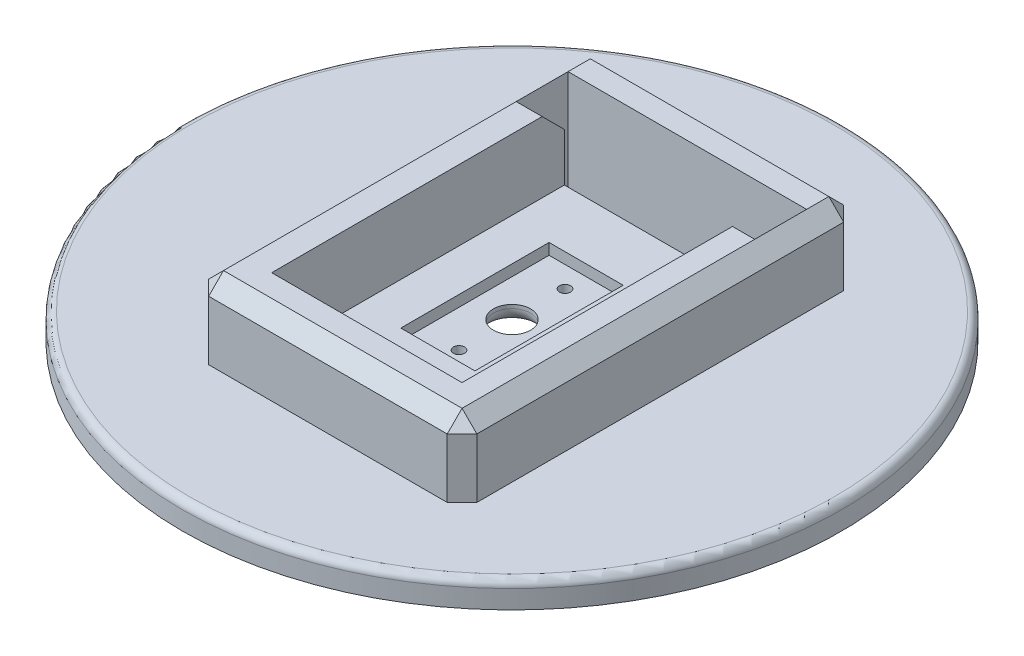
from build123d import *

# Parameters (mm, degrees)
SKETCH1_R           = 44.45
BOSS_EXTRUDE1_DEPTH = 3.5
CUT_EXTRUDE1_DEPTH  = 1
SKETCH3_W           = 25.675
SKETCH3_H           = 43.475
BOSS_EXTRUDE2_DEPTH = 10
SKETCH4_W           = 25.675
SKETCH4_H           = 4
CUT_EXTRUDE2_DEPTH  = 13
SKETCH5_R           = 0.75
CUT_EXTRUDE3_DEPTH  = 13
SKETCH6_R           = 2.5
CUT_EXTRUDE4_DEPTH  = 13
FILLET1_R           = 1
CHAMFER1_SIZE       = 2
FILLET2_R           = 2
SKETCH8_W           = 3.5
SKETCH8_H           = 4
CUT_EXTRUDE6_DEPTH  = 14.5000001
SKETCH10_W          = 3
SKETCH10_H          = 4
CUT_EXTRUDE7_DEPTH  = 14.5000001
CHAMFER2_SIZE       = 3
SKETCH11_W          = 25.675
SKETCH11_H          = 39.475
BOSS_EXTRUDE3_DEPTH = 1.5


with BuildPart() as part:
    # Sketch1 → Boss-Extrude1 (new body)
    with BuildSketch(Plane(origin=(0, 0, 0), x_dir=(1, 0, 0), z_dir=(0, 1, 0))):
        Circle(SKETCH1_R)
    extrude(amount=BOSS_EXTRUDE1_DEPTH)

    # Sketch2 → Cut-Extrude1 (cut)
    with BuildSketch(Plane(origin=(0, 3.5, 0), x_dir=(1, 0, 0), z_dir=(0, 1, 0))):
        Polygon((15, 0), (15, -21.7375), (-10.675, -21.7375), (-10.675, 21.7375), (15, 21.7375), align=None)
    extrude(amount=-CUT_EXTRUDE1_DEPTH, mode=Mode.SUBTRACT)

    # Sketch3 → Boss-Extrude2 (add)
    with BuildSketch(Plane(origin=(0, 3.5, 0), x_dir=(1, 0, 0), z_dir=(0, 1, 0))):
        Polygon((20, -26.7375), (15, -26.7375), (-16.175, -26.7375), (-16.175, 26.7375), (20, 26.7375), align=None)
        with Locations((2.1625, 0)):
            Rectangle(SKETCH3_W, SKETCH3_H, mode=Mode.SUBTRACT)
    extrude(amount=BOSS_EXTRUDE2_DEPTH)

    # Sketch4 → Cut-Extrude2 (cut)
    with BuildSketch(Plane(origin=(0, 2.5, 0), x_dir=(1, 0, 0), z_dir=(0, 1, 0))):
        with Locations((2.1625, 19.7375)):
            Rectangle(SKETCH4_W, SKETCH4_H)
    extrude(amount=-CUT_EXTRUDE2_DEPTH, mode=Mode.SUBTRACT)

    # Sketch5 → Cut-Extrude3 (cut)
    with BuildSketch(Plane(origin=(0, 2.5, 0), x_dir=(1, 0, 0), z_dir=(0, 1, 0))):
        with Locations((0, -7.15)):
            Circle(SKETCH5_R)
        with Locations((0, 7.15)):
            Circle(SKETCH5_R)
    extrude(amount=-CUT_EXTRUDE3_DEPTH, mode=Mode.SUBTRACT)

    # Sketch6 → Cut-Extrude4 (cut)
    with BuildSketch(Plane.XZ):
        Circle(SKETCH6_R)
    extrude(amount=-CUT_EXTRUDE4_DEPTH, mode=Mode.SUBTRACT)

    # Fillet1
    fillet1_edges = [part.edges().sort_by_distance(p)[0] for p in [
        (-44.45, 3.5, 0),
    ]]
    fillet(fillet1_edges, radius=FILLET1_R)

    # Chamfer1
    chamfer1_edges = [part.edges().sort_by_distance(p)[0] for p in [
        (1.9125, 13.5, 26.7375),
        (-16.175, 8.5, 26.7375),
        (20, 13.5, 0),
        (20, 8.5, 26.7375),
        (1.9125, 13.5, -26.7375),
        (20, 8.5, -26.7375),
        (-16.175, 13.5, 0),
        (-16.175, 8.5, -26.7375),
    ]]
    chamfer(chamfer1_edges, length=CHAMFER1_SIZE)

    # Fillet2
    fillet2_edges = [part.edges().sort_by_distance(p)[0] for p in [
        (-2.5, 0, 0),
    ]]
    fillet(fillet2_edges, radius=FILLET2_R)

    # Sketch8 → Cut-Extrude6 (cut, through all)
    with BuildSketch(Plane(origin=(0, 13.5, 0), x_dir=(1, 0, 0), z_dir=(0, 1, 0))):
        with Locations((-12.425, 19.7375)):
            Rectangle(SKETCH8_W, SKETCH8_H)
    extrude(amount=-CUT_EXTRUDE6_DEPTH, mode=Mode.SUBTRACT)

    # Sketch10 → Cut-Extrude7 (cut, through all)
    with BuildSketch(Plane(origin=(0, 13.5, 0), x_dir=(1, 0, 0), z_dir=(0, 1, 0))):
        with Locations((16.5, 19.7375)):
            Rectangle(SKETCH10_W, SKETCH10_H)
    extrude(amount=-CUT_EXTRUDE7_DEPTH, mode=Mode.SUBTRACT)

    # Chamfer2
    chamfer2_edges = [part.edges().sort_by_distance(p)[0] for p in [
        (-12.425, 13.5, -17.7375),
        (16.5, 13.5, -17.7375),
    ]]
    chamfer(chamfer2_edges, length=CHAMFER2_SIZE)

    # Sketch11 → Boss-Extrude3 (add)
    with BuildSketch(Plane(origin=(0, 2.5, 0), x_dir=(1, 0, 0), z_dir=(0, 1, 0))):
        with Locations((2.1625, -2)):
            Rectangle(SKETCH11_W, SKETCH11_H)
        Polygon((-5, 10), (5, 10), (5, 0), (5, -10), (-5, -10), align=None, mode=Mode.SUBTRACT)
    extrude(amount=BOSS_EXTRUDE3_DEPTH)


solid = part.part
